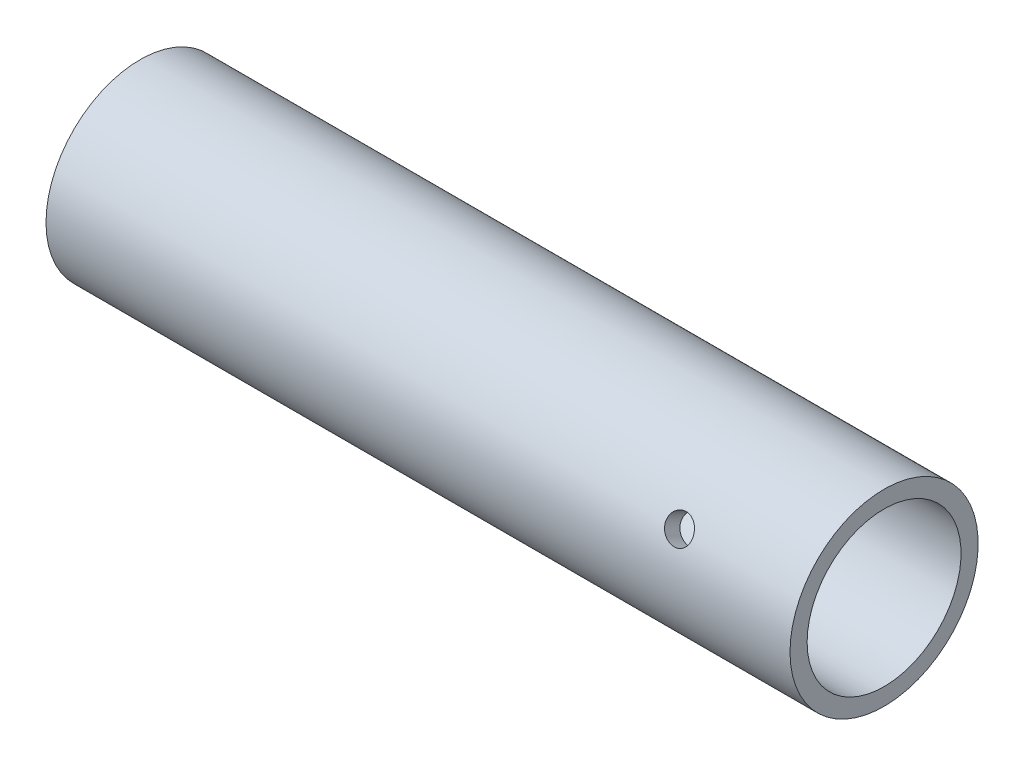
from build123d import *

# Parameters (mm, degrees)
SKETCH4_R          = 0.8
CUT_EXTRUDE1_DEPTH = 336.963729195


with BuildPart() as part:
    # Sketch3 → Revolve19 (revolve)
    with BuildSketch(Plane.XY):
        Polygon((295.058388758, -144.573704322), (295.058388758, -144.073704322), (305.058388758, -144.073704322), (305.058388758, -143.073704322), (261.558388758, -143.073704322), (261.558388758, -144.323704322), (261.558388758, -148.073704322), (263.058388758, -148.073704322), (263.058388758, -144.573704322), align=None)
    revolve(axis=Axis((263.058388758, -148.573704322, 0), (1, 0, 0)))

    # Sketch4 → Cut-Extrude1 (cut, through all)
    with BuildSketch(Plane(origin=(0, -26.447590039, -53.851341485), x_dir=(1, 0, 0), z_dir=(0, 0.4408273328513724, 0.8975919243237127))):
        with Locations((298.024345503, -133.358557166)):
            Circle(SKETCH4_R)
    extrude(amount=-CUT_EXTRUDE1_DEPTH, mode=Mode.SUBTRACT)


solid = part.part
